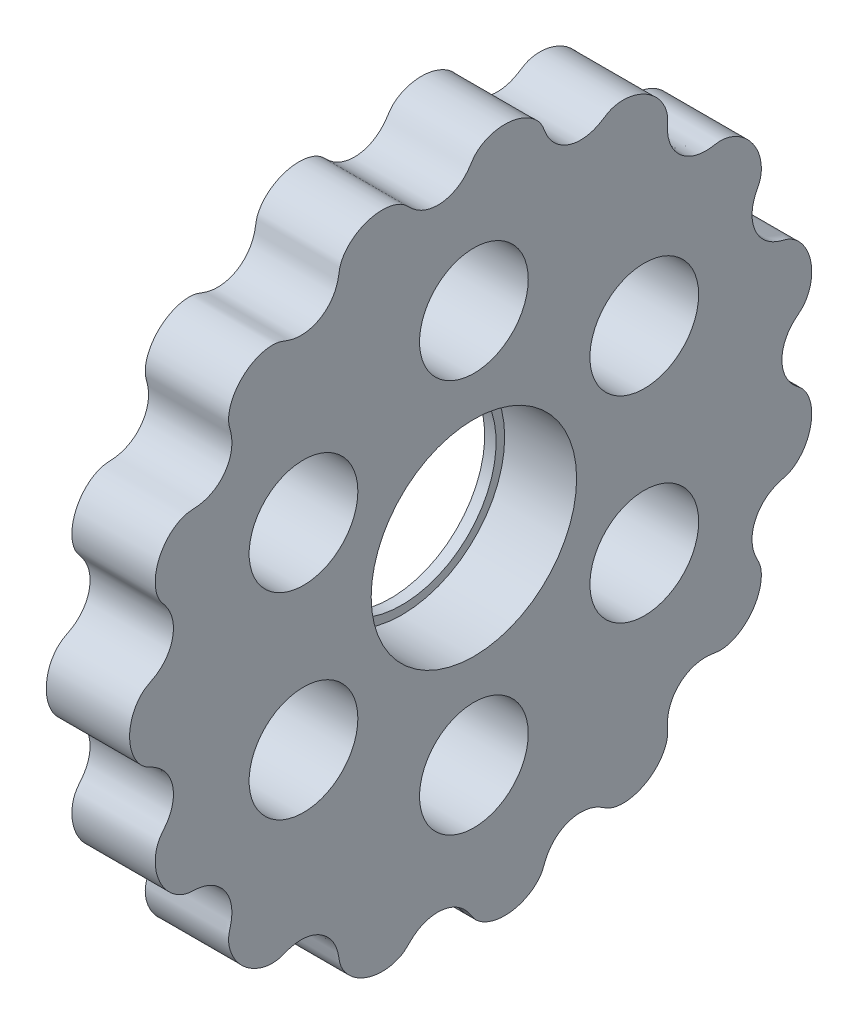
from build123d import *

# Parameters (mm, degrees)
BOSS_EXTRUDE1_START = 5.0094
SKETCH6_R           = 9
SKETCH6_R_2         = 4.7625
BOSS_EXTRUDE1_DEPTH = 7.303


with BuildPart() as part:
    # Sketch4 → Revolve1 (revolve)
    with BuildSketch(Plane.XY):
        Polygon((6.0094, 9), (9.9794, 9), (12.3124, 9), (12.3124, 12.476), (5.0094, 12.476), (5.0094, 8.25), (6.0094, 8.25), align=None)
    revolve(axis=Axis((0, 0, 0), (1, 0, 0)))

    # Sketch6 → Boss-Extrude1 (add)
    with BuildSketch(Plane(origin=(0, 0, 0), x_dir=(0, 0, -1), z_dir=(1, 0, 0)).offset(BOSS_EXTRUDE1_START)):
        with BuildLine():
            add(Edge.make_bspline(
                [(26.9875, 0), (26.9875, -0.024764), (26.98817, -0.074347), (26.991183, -0.161295), (26.999212, -0.284944), (27.014248, -0.43232), (27.04026, -0.599413), (27.082128, -0.796507), (27.145508, -1.017737), (27.22406, -1.233566), (27.317341, -1.443715), (27.432936, -1.662267), (27.573854, -1.886378), (27.742732, -2.112478), (27.941651, -2.336523), (28.130473, -2.518396), (28.300692, -2.664707), (28.445723, -2.782816), (28.561692, -2.877453), (28.67451, -2.975806), (28.781308, -3.080716), (28.90574, -3.220569), (29.048197, -3.410831), (29.197044, -3.657638), (29.375842, -4.044724), (29.529107, -4.550187), (29.615196, -5.161191), (29.593312, -5.875816), (29.450681, -6.586881), (29.186044, -7.273344), (28.846133, -7.831035), (28.481808, -8.254947), (28.137508, -8.553566), (27.879243, -8.728365), (27.648393, -8.849565), (27.415418, -8.943788), (27.214354, -9.002932), (27.011827, -9.055436), (26.770915, -9.12625), (26.533388, -9.208184), (26.263433, -9.32311), (25.968513, -9.482717), (25.553787, -9.762277), (25.067769, -10.221633), (24.628091, -10.894849), (24.36131, -11.787754), (24.345876, -12.609736), (24.47642, -13.236613), (24.652481, -13.70056), (24.805849, -14.020184), (24.938249, -14.271023), (25.050296, -14.532129), (25.125821, -14.80638), (25.173615, -15.099529), (25.19109, -15.409372), (25.17415, -15.816346), (25.089085, -16.314763), (24.906992, -16.876408), (24.51824, -17.631479), (23.97568, -18.294201), (23.36955, -18.776362), (22.756373, -19.084012), (22.364085, -19.219861), (22.055396, -19.292319), (21.753289, -19.328857), (21.461152, -19.329551), (21.172324, -19.289622), (20.885242, -19.241739), (20.595569, -19.210428), (20.304314, -19.199389), (19.86692, -19.217661), (19.289903, -19.323063), (18.583273, -19.609237), (17.844394, -20.183416), (17.380715, -20.82804), (17.131587, -21.423972), (17.018209, -21.887901), (16.971413, -22.197068), (16.953661, -22.470085), (16.953282, -22.704385), (16.961877, -22.938429), (16.973701, -23.133257), (16.977032, -23.32862), (16.959369, -23.562361), (16.917686, -23.810051), (16.833985, -24.105462), (16.657848, -24.527607), (16.362281, -25.015071), (15.927775, -25.519801), (15.343153, -25.989981), (14.695679, -26.347176), (14.00682, -26.585727), (13.385571, -26.685139), (12.847022, -26.68493), (12.416642, -26.622378), (12.132391, -26.546774), (11.905805, -26.459761), (11.734224, -26.37532), (11.601738, -26.298938), (11.472674, -26.216887), (11.3444, -26.133673), (11.18252, -26.032158), (10.983572, -25.917906), (10.743479, -25.799113), (10.458738, -25.686653), (10.010565, -25.553568), (9.38431, -25.467962), (8.599049, -25.536252), (7.724322, -25.877301), (7.109332, -26.34587), (6.715998, -26.804193), (6.47446, -27.184133), (6.335199, -27.448863), (6.215028, -27.722663), (6.111289, -28.00278), (5.995931, -28.27892), (5.840956, -28.535713), (5.652236, -28.779191), (5.431634, -29.00697), (5.118848, -29.27106), (4.6965, -29.543893), (4.162392, -29.788243), (3.548707, -29.956437), (2.952085, -30.029605), (2.386007, -30.022532), (1.859535, -29.949035), (1.340883, -29.805477), (0.905819, -29.614717), (0.554361, -29.400407), (0.282828, -29.183226), (0.084708, -28.987474), (-0.086509, -28.767965), (-0.235281, -28.533203), (-0.390374, -28.301592), (-0.559762, -28.078607), (-0.792018, -27.814635), (-1.103561, -27.527431), (-1.510454, -27.244824), (-2.068787, -26.98343), (-2.71666, -26.820245), (-3.458994, -26.794886), (-4.152923, -26.940729), (-4.722431, -27.189881), (-5.129595, -27.454974), (-5.386596, -27.660998), (-5.592527, -27.850724), (-5.755763, -28.01403), (-5.919893, -28.176591), (-6.097653, -28.324551), (-6.338167, -28.485085), (-6.690609, -28.662784), (-7.166875, -28.818239), (-7.766767, -28.907642), (-8.420126, -28.895664), (-9.074669, -28.78036), (-9.714439, -28.56137), (-10.32166, -28.23814), (-10.806085, -27.863617), (-11.167055, -27.483672), (-11.414252, -27.140205), (-11.573427, -26.858964), (-11.694647, -26.572962), (-11.773542, -26.285682), (-11.817264, -25.991542), (-11.866816, -25.69877), (-11.935294, -25.409346), (-12.025677, -25.126053), (-12.197958, -24.70909), (-12.508917, -24.186955), (-13.037889, -23.619068), (-13.844765, -23.135473), (-14.607195, -22.936463), (-15.236885, -22.91489), (-15.701026, -22.969431), (-16.002433, -23.031649), (-16.260923, -23.107034), (-16.478173, -23.184134), (-16.657576, -23.252859), (-16.80146, -23.306955), (-16.983915, -23.367243), (-17.208691, -23.420291), (-17.485287, -23.453351), (-17.810971, -23.45435), (-18.229097, -23.410378), (-18.730492, -23.288537), (-19.28843, -23.059981), (-19.860265, -22.705168), (-20.358127, -22.276359), (-20.775839, -21.789866), (-21.108558, -21.259767), (-21.333593, -20.731774), (-21.461915, -20.2263), (-21.500604, -19.811267), (-21.488894, -19.498948), (-21.446802, -19.242413), (-21.396546, -19.040794), (-21.339975, -18.833239), (-21.287848, -18.616789), (-21.234069, -18.332201), (-21.196175, -17.977321), (-21.198512, -17.560353), (-21.278053, -17.017315), (-21.472071, -16.425591), (-21.837967, -15.786074), (-22.348241, -15.257818), (-22.894638, -14.895669), (-23.382847, -14.687762), (-23.736837, -14.583426), (-24.053619, -14.52154), (-24.328453, -14.487593), (-24.604545, -14.470007), (-24.881071, -14.457997), (-25.155551, -14.418375), (-25.422771, -14.343923), (-25.693179, -14.237455), (-26.110882, -14.021815), (-26.567717, -13.682153), (-27.025831, -13.198123), (-27.431383, -12.568184), (-27.701704, -11.957799), (-27.874597, -11.311225), (-27.933245, -10.726994), (-27.911148, -10.224728), (-27.841519, -9.821434), (-27.756818, -9.515929), (-27.642699, -9.22983), (-27.500442, -8.965879), (-27.3212, -8.72613), (-27.130119, -8.496555), (-26.907128, -8.196705), (-26.64175, -7.758255), (-26.399733, -7.150775), (-26.284143, -6.387452), (-26.364207, -5.579774), (-26.601908, -4.905544), (-26.919309, -4.376057), (-27.273556, -3.963559), (-27.582979, -3.690383), (-27.871886, -3.487057), (-28.118618, -3.340673), (-28.313549, -3.237061), (-28.504345, -3.141113), (-28.685419, -3.041883), (-28.900216, -2.898363), (-29.135521, -2.695824), (-29.412318, -2.388156), (-29.695848, -1.955164), (-29.931957, -1.437005), (-30.098529, -0.839035), (-30.17792, -0.202544), (-30.160262, 0.459906), (-30.034766, 1.132309), (-29.819916, 1.711033), (-29.561731, 2.171908), (-29.303527, 2.511832), (-29.078439, 2.748026), (-28.865455, 2.924047), (-28.676106, 3.046785), (-28.511237, 3.136712), (-28.377456, 3.205046), (-28.21058, 3.291099), (-28.013597, 3.400533), (-27.791241, 3.541326), (-27.550757, 3.721931), (-27.2011, 4.034254), (-26.794052, 4.528474), (-26.44194, 5.233958), (-26.277736, 6.149359), (-26.351046, 6.90812), (-26.526777, 7.473881), (-26.721793, 7.882292), (-26.861901, 8.119629), (-26.99529, 8.314389), (-27.137284, 8.502849), (-27.261339, 8.655276), (-27.384488, 8.808816), (-27.517956, 9.003504), (-27.632439, 9.210345), (-27.74125, 9.469327), (-27.832645, 9.781395), (-27.907424, 10.188464), (-27.934481, 10.691308), (-27.880804, 11.277105), (-27.687764, 12.022936), (-27.316617, 12.811091), (-26.840488, 13.427816), (-26.324331, 13.871788), (-25.911827, 14.126315), (-25.650297, 14.256573), (-25.376944, 14.359613), (-25.0933, 14.431764), (-24.802705, 14.463382), (-24.511203, 14.473788), (-24.162885, 14.503285), (-23.760808, 14.571702), (-23.188742, 14.744311), (-22.551107, 15.090106), (-21.96196, 15.623112), (-21.543972, 16.274887), (-21.321692, 16.856997), (-21.217457, 17.385115), (-21.190172, 17.839694), (-21.218479, 18.237399), (-21.277133, 18.573922), (-21.344308, 18.850611), (-21.404955, 19.070618), (-21.457862, 19.292831), (-21.488339, 19.51944), (-21.498067, 19.805007), (-21.466366, 20.19075), (-21.35646, 20.667179), (-21.133065, 21.213475), (-20.802529, 21.754132), (-20.388181, 22.246103), (-19.897364, 22.676976), (-19.337935, 23.032988), (-18.796436, 23.264893), (-18.309013, 23.394133), (-17.898124, 23.44826), (-17.572648, 23.457184), (-17.29241, 23.433085), (-17.060158, 23.387419), (-16.833673, 23.319933), (-16.649476, 23.249911), (-16.465893, 23.179098), (-16.242397, 23.102515), (-16.015551, 23.036171), (-15.74608, 22.976761), (-15.296654, 22.918471), (-14.703457, 22.927752), (-13.959205, 23.094831), (-13.14068, 23.536494), (-12.580499, 24.090806), (-12.238155, 24.630904), (-12.050456, 25.059851), (-11.953776, 25.344172), (-11.889154, 25.5989), (-11.846349, 25.819797), (-11.816242, 26.004848), (-11.792554, 26.152972), (-11.757677, 26.337226), (-11.698897, 26.55475), (-11.596855, 26.8111), (-11.441444, 27.09748), (-11.197725, 27.447264), (-10.839175, 27.834319), (-10.355428, 28.21657), (-9.754917, 28.543091), (-9.130275, 28.76422), (-8.499981, 28.885078), (-7.87902, 28.910962), (-7.31263, 28.845836), (-6.812777, 28.709116), (-6.434466, 28.540032), (-6.169155, 28.37801), (-5.966498, 28.217286), (-5.816284, 28.075241), (-5.665892, 27.923245), (-5.506723, 27.769877), (-5.290672, 27.580585), (-5.007233, 27.368976), (-4.65088, 27.159689), (-4.147956, 26.951298), (-3.545198, 26.814597), (-2.830207, 26.799081), (-2.038117, 26.974949), (-1.349481, 27.32247), (-0.848312, 27.741004), (-0.514589, 28.129055), (-0.299066, 28.433772), (-0.140083, 28.686239), (0.033075, 28.930014), (0.240491, 29.14605), (0.477448, 29.34225), (0.741803, 29.516512), (1.103643, 29.706564), (1.57406, 29.881983), (2.147144, 30.006048), (2.81506, 30.040954), (3.479066, 29.972097), (4.203936, 29.780428), (4.806414, 29.493329), (5.270826, 29.162753), (5.604852, 28.831106), (5.789408, 28.606173), (5.942408, 28.374393), (6.06422, 28.124922), (6.160969, 27.865277), (6.26348, 27.607979), (6.381255, 27.357004), (6.538795, 27.074815), (6.74842, 26.770448), (7.098587, 26.370671), (7.613473, 25.964102), (8.27467, 25.644036), (8.996164, 25.495939), (9.618093, 25.49602), (10.158161, 25.589428), (10.554566, 25.716768), (10.879594, 25.862901), (11.133059, 26.002206), (11.322426, 26.118759), (11.502111, 26.236625), (11.678353, 26.346322), (11.909435, 26.464883), (12.202801, 26.571764), (12.609209, 26.662394), (13.129064, 26.695793), (13.700037, 26.644377), (14.306153, 26.491437), (14.897445, 26.244272), (15.45898, 25.902933), (15.973216, 25.468084), (16.363084, 25.007134), (16.633726, 24.567043), (16.804398, 24.182209), (16.903645, 23.871559), (16.957142, 23.597784), (16.975498, 23.367245), (16.974096, 23.174827), (16.96695, 23.021066), (16.957079, 22.828939), (16.951217, 22.598163), (16.9599, 22.328669), (16.994585, 22.022435), (17.087364, 21.563771), (17.304349, 20.971375), (17.731459, 20.308695), (18.442645, 19.693023), (19.146758, 19.367735), (19.738967, 19.235106), (20.188242, 19.201207), (20.485213, 19.203437), (20.781216, 19.228215), (21.074517, 19.271948), (21.367486, 19.320796), (21.664758, 19.333565), (21.973742, 19.305989), (22.289868, 19.240978), (22.692166, 19.111561), (23.164144, 18.885385), (23.669018, 18.540404), (24.16338, 18.062816), (24.568977, 17.521881), (24.88071, 16.934509), (25.093711, 16.315954), (25.184007, 15.774292), (25.192436, 15.331657), (25.158072, 14.996894), (25.115438, 14.769508), (25.052239, 14.54678), (24.965803, 14.332085), (24.861614, 14.125722), (24.756805, 13.91979), (24.640202, 13.664872), (24.524031, 13.356172), (24.398459, 12.886018), (24.338851, 12.266306), (24.416597, 11.560499), (24.697883, 10.793099), (25.09522, 10.204239), (25.542599, 9.770561), (25.955058, 9.488292), (26.268852, 9.320846), (26.56271, 9.197124), (26.830006, 9.106188), (27.101857, 9.031519), (27.374937, 8.959769), (27.638525, 8.857378), (27.886998, 8.722488), (28.196877, 8.509826), (28.5449, 8.193561), (28.900229, 7.754886), (29.222891, 7.181659), (29.452887, 6.561951), (29.58577, 5.910762), (29.616505, 5.243181), (29.548546, 4.658974), (29.418832, 4.172502), (29.263566, 3.793143), (29.114413, 3.512871), (28.940427, 3.258184), (28.743215, 3.031731), (28.515468, 2.837052), (28.280974, 2.651472), (28.057772, 2.451915), (27.84918, 2.237099), (27.634728, 1.976085), (27.457408, 1.710216), (27.315195, 1.444422), (27.204745, 1.184469), (27.130719, 0.970324), (27.078886, 0.779299), (27.044074, 0.616428), (27.020981, 0.471969), (27.006068, 0.351049), (26.998146, 0.266234), (26.994627, 0.217571), (26.993193, 0.193247)],
                knots=[0.06864, 0.06864, 0.06864, 0.06864, 0.06864, 0.069106, 0.069571, 0.070037, 0.070502, 0.071433, 0.072364, 0.073295, 0.074226, 0.075157, 0.076088, 0.077301, 0.078514, 0.079727, 0.08094, 0.081547, 0.082153, 0.08276, 0.083366, 0.083973, 0.084579, 0.085792, 0.087214, 0.088636, 0.091479, 0.094323, 0.097166, 0.100174, 0.103182, 0.10619, 0.107694, 0.109198, 0.110555, 0.111234, 0.111912, 0.113269, 0.113948, 0.114626, 0.115983, 0.11734, 0.118697, 0.120055, 0.12408, 0.128106, 0.131537, 0.134967, 0.137266, 0.138415, 0.139565, 0.140714, 0.141863, 0.143013, 0.144162, 0.145524, 0.146885, 0.149608, 0.152331, 0.155054, 0.160594, 0.163364, 0.164749, 0.166134, 0.167314, 0.168495, 0.169675, 0.170855, 0.172035, 0.173215, 0.174395, 0.175575, 0.179125, 0.182676, 0.186612, 0.190548, 0.191813, 0.193079, 0.194345, 0.195611, 0.196244, 0.196877, 0.198142, 0.198775, 0.199408, 0.200674, 0.202207, 0.203741, 0.206808, 0.209874, 0.212941, 0.21584, 0.218738, 0.221637, 0.223086, 0.224535, 0.225775, 0.226394, 0.227014, 0.227634, 0.228253, 0.228873, 0.229493, 0.230732, 0.231971, 0.233211, 0.23445, 0.238303, 0.242155, 0.245814, 0.249472, 0.250683, 0.251894, 0.253105, 0.254316, 0.255527, 0.256738, 0.257949, 0.25916, 0.260514, 0.261868, 0.264577, 0.267285, 0.269993, 0.272142, 0.27429, 0.276439, 0.278588, 0.280839, 0.281965, 0.283091, 0.284217, 0.285343, 0.286469, 0.287595, 0.288737, 0.289879, 0.292163, 0.294447, 0.296732, 0.299827, 0.302922, 0.306383, 0.308113, 0.309844, 0.31078, 0.311716, 0.312652, 0.313588, 0.314524, 0.31546, 0.317332, 0.319969, 0.322606, 0.325244, 0.327881, 0.330703, 0.333524, 0.336346, 0.337757, 0.339168, 0.340372, 0.341576, 0.34278, 0.343984, 0.345188, 0.346392, 0.347596, 0.3488, 0.352495, 0.356189, 0.36002, 0.36385, 0.365096, 0.366342, 0.367588, 0.368834, 0.369457, 0.370079, 0.370702, 0.371325, 0.372571, 0.373817, 0.375207, 0.376596, 0.379375, 0.382154, 0.384933, 0.387459, 0.389986, 0.392513, 0.39504, 0.396723, 0.398407, 0.399249, 0.400091, 0.400932, 0.401774, 0.402737, 0.4037, 0.405625, 0.407551, 0.409476, 0.412569, 0.415662, 0.41939, 0.421254, 0.423119, 0.42424, 0.425361, 0.426483, 0.427604, 0.428726, 0.429847, 0.430969, 0.43209, 0.433431, 0.437455, 0.440138, 0.44282, 0.445528, 0.448236, 0.450943, 0.452297, 0.453651, 0.454862, 0.456073, 0.457284, 0.458495, 0.459706, 0.460916, 0.463338, 0.466783, 0.470228, 0.473297, 0.476366, 0.478273, 0.480179, 0.482085, 0.483038, 0.483991, 0.484828, 0.485664, 0.486501, 0.487337, 0.48901, 0.490683, 0.493189, 0.495695, 0.498202, 0.500708, 0.503552, 0.506397, 0.509241, 0.510663, 0.512085, 0.513303, 0.514521, 0.51513, 0.515738, 0.516347, 0.516956, 0.518174, 0.519391, 0.520609, 0.521827, 0.525766, 0.529706, 0.533208, 0.53671, 0.537985, 0.53926, 0.540535, 0.541173, 0.54181, 0.543085, 0.543723, 0.54436, 0.545635, 0.54691, 0.548267, 0.549623, 0.552335, 0.555047, 0.55776, 0.562061, 0.566363, 0.567545, 0.568728, 0.56991, 0.571092, 0.572275, 0.573457, 0.574639, 0.575822, 0.577939, 0.580057, 0.584292, 0.587472, 0.590653, 0.592493, 0.594334, 0.596174, 0.598014, 0.59894, 0.599865, 0.60079, 0.601715, 0.60264, 0.603565, 0.605415, 0.607973, 0.610531, 0.61309, 0.615648, 0.618364, 0.62108, 0.623796, 0.625154, 0.626512, 0.627788, 0.629065, 0.629703, 0.630341, 0.631618, 0.632256, 0.632895, 0.634171, 0.635448, 0.636724, 0.640232, 0.643739, 0.647674, 0.651609, 0.652825, 0.65404, 0.655256, 0.656472, 0.65708, 0.657688, 0.658296, 0.658904, 0.66012, 0.661336, 0.662756, 0.664177, 0.667018, 0.669858, 0.672699, 0.675209, 0.677718, 0.680227, 0.682736, 0.684412, 0.686087, 0.686924, 0.687762, 0.688599, 0.689437, 0.690391, 0.691345, 0.693254, 0.695162, 0.697071, 0.700143, 0.703216, 0.706655, 0.710095, 0.712514, 0.713723, 0.714933, 0.716142, 0.717352, 0.718561, 0.719771, 0.721123, 0.722475, 0.725179, 0.727883, 0.730587, 0.733273, 0.735959, 0.739989, 0.741332, 0.742455, 0.743577, 0.7447, 0.745823, 0.746945, 0.748068, 0.749191, 0.750314, 0.752181, 0.754048, 0.757782, 0.760871, 0.763961, 0.765883, 0.767806, 0.769729, 0.77069, 0.771651, 0.772492, 0.773333, 0.774174, 0.775015, 0.776698, 0.77838, 0.780903, 0.783427, 0.785951, 0.788475, 0.791257, 0.794039, 0.796822, 0.798213, 0.799604, 0.800852, 0.802099, 0.802723, 0.803347, 0.803971, 0.804595, 0.805842, 0.80709, 0.808337, 0.809585, 0.81342, 0.817255, 0.820945, 0.824634, 0.825837, 0.827039, 0.828242, 0.829444, 0.830647, 0.831849, 0.833052, 0.834254, 0.835663, 0.837072, 0.83989, 0.842708, 0.845526, 0.848167, 0.850807, 0.853447, 0.856087, 0.857024, 0.857961, 0.858897, 0.859834, 0.860771, 0.861707, 0.862644, 0.863581, 0.865314, 0.867048, 0.870515, 0.873613, 0.876711, 0.880181, 0.881916, 0.883651, 0.884794, 0.885937, 0.887081, 0.888224, 0.889367, 0.89051, 0.891653, 0.892797, 0.895451, 0.898105, 0.90076, 0.903414, 0.906126, 0.908838, 0.911549, 0.912905, 0.914261, 0.915474, 0.916686, 0.917899, 0.919111, 0.920323, 0.921536, 0.922748, 0.923961, 0.925793, 0.926709, 0.927625, 0.928541, 0.929457, 0.929915, 0.930373, 0.930831, 0.931289, 0.931289, 0.931289, 0.931289, 0.931289], degree=4))
            ThreePointArc((26.993193, 0.193247), (26.988924, 0.096666), (26.9875, 0))
        make_face()
        Circle(SKETCH6_R, mode=Mode.SUBTRACT)
        with Locations((-14.928979, 8.61925)):
            Circle(SKETCH6_R_2, mode=Mode.SUBTRACT)
        with Locations((0, 17.2385)):
            Circle(SKETCH6_R_2, mode=Mode.SUBTRACT)
        with Locations((14.928979, 8.61925)):
            Circle(SKETCH6_R_2, mode=Mode.SUBTRACT)
        with Locations((14.928979, -8.61925)):
            Circle(SKETCH6_R_2, mode=Mode.SUBTRACT)
        with Locations((0, -17.2385)):
            Circle(SKETCH6_R_2, mode=Mode.SUBTRACT)
        with Locations((-14.928979, -8.61925)):
            Circle(SKETCH6_R_2, mode=Mode.SUBTRACT)
    extrude(amount=BOSS_EXTRUDE1_DEPTH)


solid = part.part
